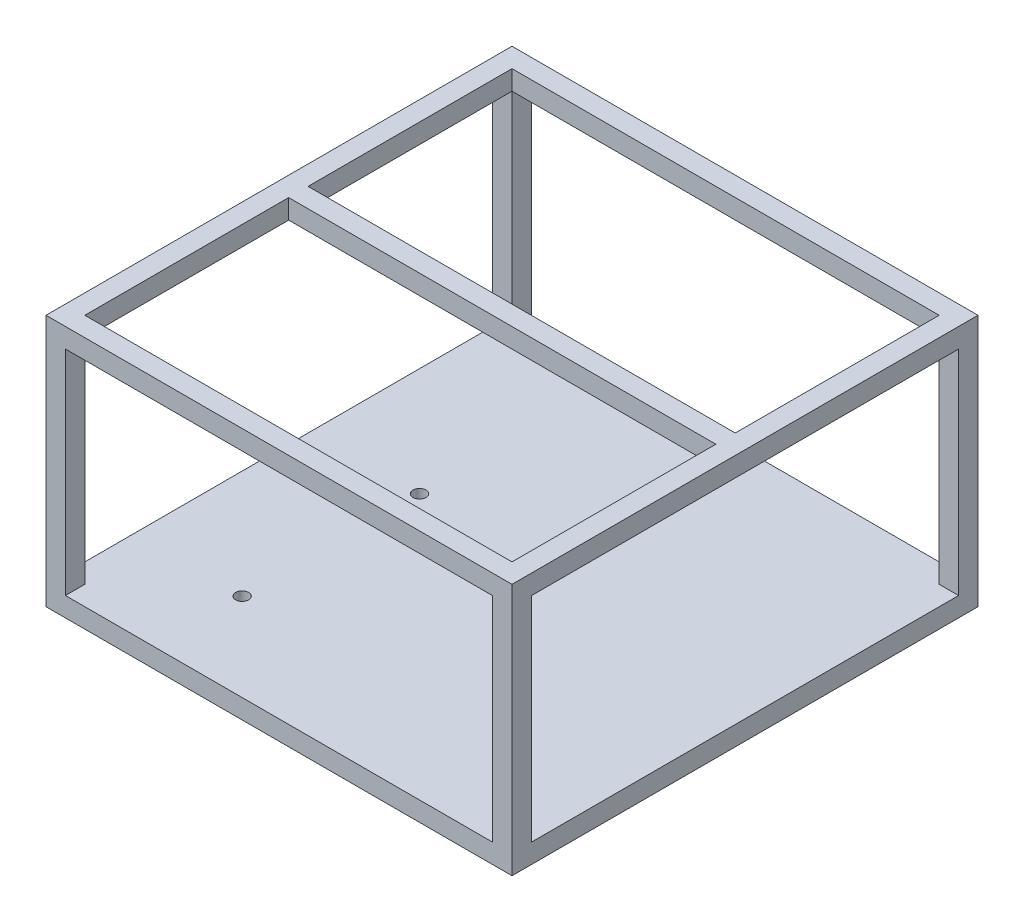
from build123d import *

# Parameters (mm, degrees)
SKETCH1_W           = 152.4
SKETCH1_H           = 152.4
BOSS_EXTRUDE1_DEPTH = 6.35
SKETCH2_R           = 2.125
CUT_EXTRUDE1_DEPTH  = 6.35
SKETCH3_W           = 6.35
SKETCH3_H           = 6.35
BOSS_EXTRUDE2_DEPTH = 76.2
SKETCH4_W           = 6.35
SKETCH4_H           = 6.384095646
BOSS_EXTRUDE3_DEPTH = 139.7
SKETCH5_W           = 6.35
SKETCH5_H           = 6.384095646
BOSS_EXTRUDE4_DEPTH = 139.7
SKETCH6_W           = 6.35
SKETCH6_H           = 6.384095646
BOSS_EXTRUDE5_DEPTH = 139.7


with BuildPart() as part:
    # Sketch1 → Boss-Extrude1 (new body)
    with BuildSketch(Plane(origin=(0, 0, 0), x_dir=(1, 0, 0), z_dir=(0, 1, 0))):
        with Locations((40.776583963, 45.362139437)):
            Rectangle(SKETCH1_W, SKETCH1_H)
    extrude(amount=BOSS_EXTRUDE1_DEPTH)

    # Sketch2 → Cut-Extrude1 (cut)
    with BuildSketch(Plane(origin=(0, 6.35, 0), x_dir=(1, 0, 0), z_dir=(0, 1, 0))):
        with Locations((0, -2.125)):
            Circle(SKETCH2_R)
        with Locations((0, 55.889)):
            Circle(SKETCH2_R)
    extrude(amount=-CUT_EXTRUDE1_DEPTH, mode=Mode.SUBTRACT)

    # Sketch3 → Boss-Extrude2 (add)
    with BuildSketch(Plane(origin=(0, 6.35, 0), x_dir=(1, 0, 0), z_dir=(0, 1, 0))):
        with Locations((113.801583963, -27.662860563)):
            Rectangle(SKETCH3_W, SKETCH3_H)
        with Locations((-32.248416037, -27.662860563)):
            Rectangle(SKETCH3_W, SKETCH3_H)
        with Locations((-32.248416037, 118.387139437)):
            Rectangle(SKETCH3_W, SKETCH3_H)
        with Locations((113.801583963, 118.387139437)):
            Rectangle(SKETCH3_W, SKETCH3_H)
    extrude(amount=BOSS_EXTRUDE2_DEPTH)

    # Sketch4 → Boss-Extrude3 (add)
    with BuildSketch(Plane(origin=(0, 0, 24.487860563), x_dir=(-1, 0, 0), z_dir=(0, 0, -1))):
        with Locations((-113.801583963, 79.357952177)):
            Rectangle(SKETCH4_W, SKETCH4_H)
        with Locations((32.248416037, 79.357952177)):
            Rectangle(SKETCH4_W, SKETCH4_H)
    extrude(amount=BOSS_EXTRUDE3_DEPTH)

    # Sketch5 → Boss-Extrude4 (add)
    with BuildSketch(Plane(origin=(-29.073416037, 0, 0), x_dir=(0, 0, -1), z_dir=(1, 0, 0))):
        with Locations((-27.662860563, 79.357952177)):
            Rectangle(SKETCH5_W, SKETCH5_H)
        with Locations((118.387139437, 79.357952177)):
            Rectangle(SKETCH5_W, SKETCH5_H)
    extrude(amount=BOSS_EXTRUDE4_DEPTH)

    # Sketch6 → Boss-Extrude5 (add)
    with BuildSketch(Plane(origin=(-29.073416037, 0, 0), x_dir=(0, 0, -1), z_dir=(1, 0, 0))):
        with Locations((45.347085843, 79.357952177)):
            Rectangle(SKETCH6_W, SKETCH6_H)
    extrude(amount=BOSS_EXTRUDE5_DEPTH)


solid = part.part
